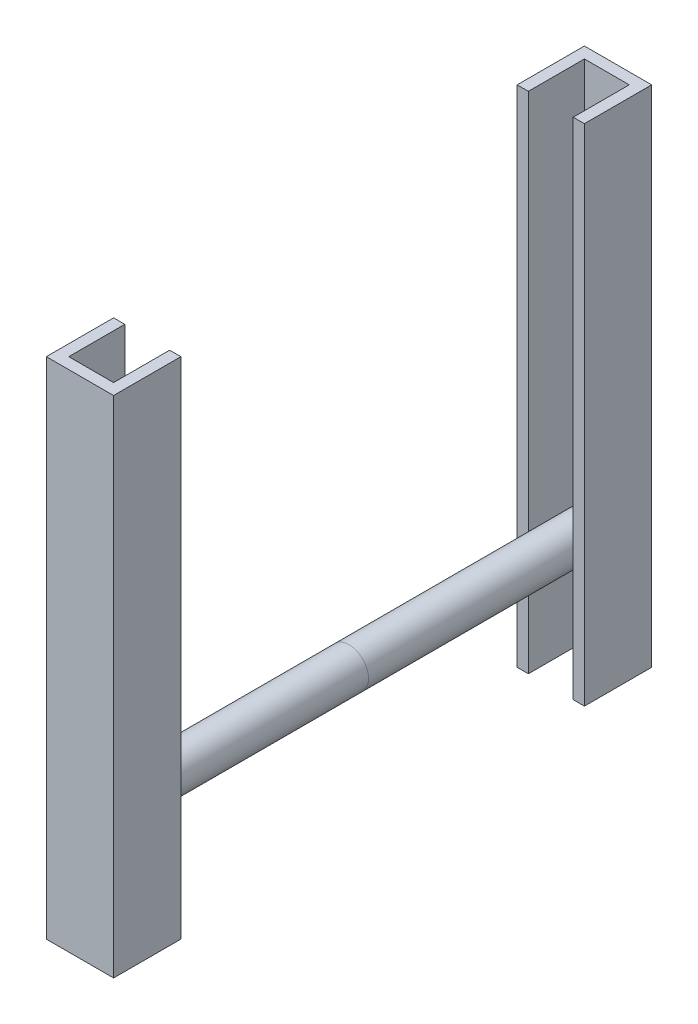
from build123d import *

# Parameters (mm, degrees)
BOSS_EXTRUDE1_DEPTH = 225
SKETCH3_R           = 17.5
BOSS_EXTRUDE2_DEPTH = 210


with BuildPart() as part:
    # Sketch2 → Boss-Extrude1 (new body, symmetric)
    with BuildSketch(Plane(origin=(0, 0, 0), x_dir=(1, 0, 0), z_dir=(0, 1, 0))):
        Polygon((-20, 20), (-20, 30), (-30, 30), (-30, -30), (30, -30), (30, 30), (20, 30), (20, 20), (20, -20), (-20, -20), align=None)
    extrude(amount=BOSS_EXTRUDE1_DEPTH, both=True)


with BuildPart() as body_2:
    # Sketch3 → Boss-Extrude2 (new body)
    with BuildSketch(Plane.XY):
        with Locations((0, -120)):
            Circle(SKETCH3_R)
    extrude(amount=-BOSS_EXTRUDE2_DEPTH)


with BuildPart() as body_3:
    # Mirror3: mirrored copy
    add(body_2.part.mirror(Plane(origin=(0, -120, -210), x_dir=(1, 0, 0), z_dir=(0, 0, 1))))


with BuildPart() as body_4:
    # Mirror3 2: mirrored copy
    add(part.part.mirror(Plane(origin=(0, -120, -210), x_dir=(1, 0, 0), z_dir=(0, 0, 1))))


solid = Compound([part.part, body_2.part, body_3.part, body_4.part])
